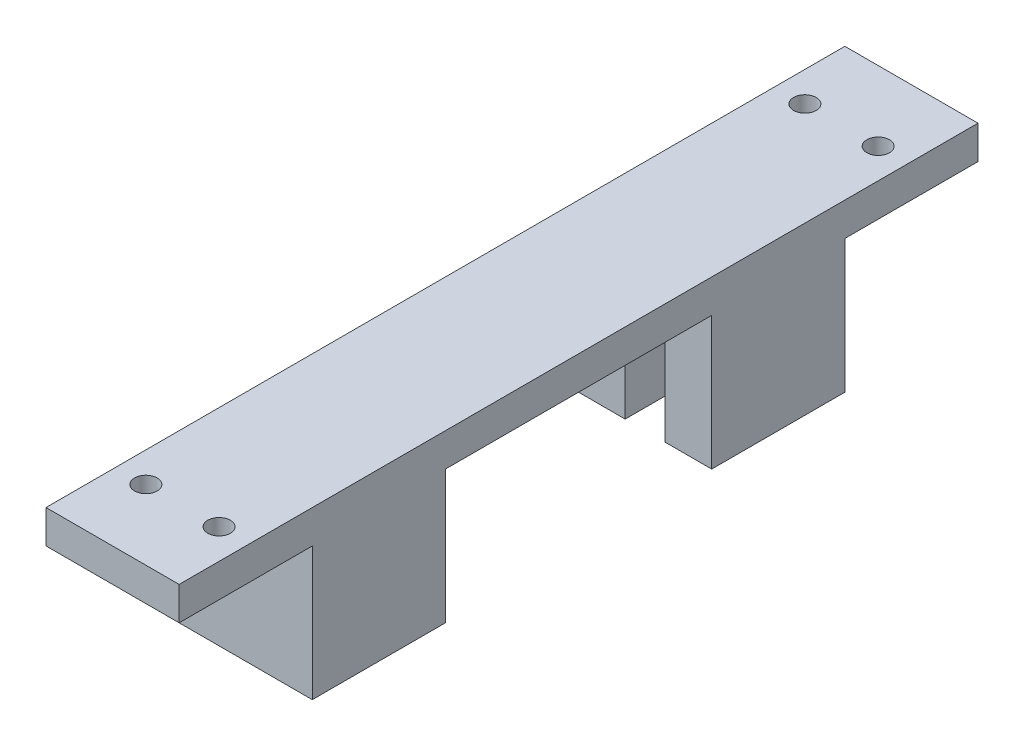
from build123d import *

# Parameters (mm, degrees)
SKETCH1_W            = 20
SKETCH1_H            = 40
BOSS_EXTRUDE1_DEPTH  = 5
SKETCH2_W            = 20
SKETCH2_H            = 20
BOSS_EXTRUDE2_DEPTH  = 20
SKETCH3_W            = 6
SKETCH3_H            = 16
CUT_EXTRUDE1_DEPTH   = 20
M3_CLEARANCE_HOLE1_D = 3.4
SKETCH6_W            = 20
SKETCH6_H            = 5
BOSS_EXTRUDE3_DEPTH  = 60
SKETCH7_W            = 20
SKETCH7_H            = 5
BOSS_EXTRUDE4_DEPTH  = 20
SKETCH8_W            = 20
SKETCH8_H            = 20
BOSS_EXTRUDE5_DEPTH  = 20
SKETCH9_W            = 6
SKETCH9_H            = 16
CUT_EXTRUDE2_DEPTH   = 20
M3_CLEARANCE_HOLE2_D = 3.4


with BuildPart() as part:
    # Sketch1 → Boss-Extrude1 (new body)
    with BuildSketch(Plane(origin=(0, 0, 0), x_dir=(1, 0, 0), z_dir=(0, 1, 0))):
        Rectangle(SKETCH1_W, SKETCH1_H)
    extrude(amount=BOSS_EXTRUDE1_DEPTH)

    # Sketch2 → Boss-Extrude2 (add)
    with BuildSketch(Plane(origin=(0, 0, 0), x_dir=(-1, 0, 0), z_dir=(0, -1, 0))):
        with Locations((0, 10)):
            Rectangle(SKETCH2_W, SKETCH2_H)
    extrude(amount=BOSS_EXTRUDE2_DEPTH)

    # Sketch3 → Cut-Extrude1 (cut)
    with BuildSketch(Plane(origin=(0, -20, 0), x_dir=(-1, 0, 0), z_dir=(0, -1, 0))):
        with Locations((0, 12)):
            Rectangle(SKETCH3_W, SKETCH3_H)
    extrude(amount=-CUT_EXTRUDE1_DEPTH, mode=Mode.SUBTRACT)

    # M3 Clearance Hole1 (through all)
    with Locations(Plane(origin=(0, 0, 0), x_dir=(-1, 0, 0), z_dir=(0, -1, 0))):
        with Locations((-5.5, -9.5), (5.5, -9.5)):
            Hole(M3_CLEARANCE_HOLE1_D / 2)

    # Sketch6 → Boss-Extrude3 (add)
    with BuildSketch(Plane(origin=(0, 0, -20), x_dir=(-1, 0, 0), z_dir=(0, 0, -1))):
        with Locations((0, 2.5)):
            Rectangle(SKETCH6_W, SKETCH6_H)
    extrude(amount=BOSS_EXTRUDE3_DEPTH)

    # Sketch7 → Boss-Extrude4 (add)
    with BuildSketch(Plane(origin=(0, 0, -80), x_dir=(-1, 0, 0), z_dir=(0, 0, -1))):
        with Locations((0, 2.5)):
            Rectangle(SKETCH7_W, SKETCH7_H)
    extrude(amount=BOSS_EXTRUDE4_DEPTH)

    # Sketch8 → Boss-Extrude5 (add)
    with BuildSketch(Plane(origin=(0, 0, 0), x_dir=(-1, 0, 0), z_dir=(0, -1, 0))):
        with Locations((0, 70)):
            Rectangle(SKETCH8_W, SKETCH8_H)
    extrude(amount=BOSS_EXTRUDE5_DEPTH)

    # Sketch9 → Cut-Extrude2 (cut)
    with BuildSketch(Plane(origin=(0, -20, 0), x_dir=(-1, 0, 0), z_dir=(0, -1, 0))):
        with Locations((0, 68)):
            Rectangle(SKETCH9_W, SKETCH9_H)
    extrude(amount=-CUT_EXTRUDE2_DEPTH, mode=Mode.SUBTRACT)

    # M3 Clearance Hole2 (through all)
    with Locations(Plane(origin=(0, 0, 0), x_dir=(-1, 0, 0), z_dir=(0, -1, 0))):
        with Locations((-5.5, 89.5), (5.5, 89.5)):
            Hole(M3_CLEARANCE_HOLE2_D / 2)


solid = part.part
